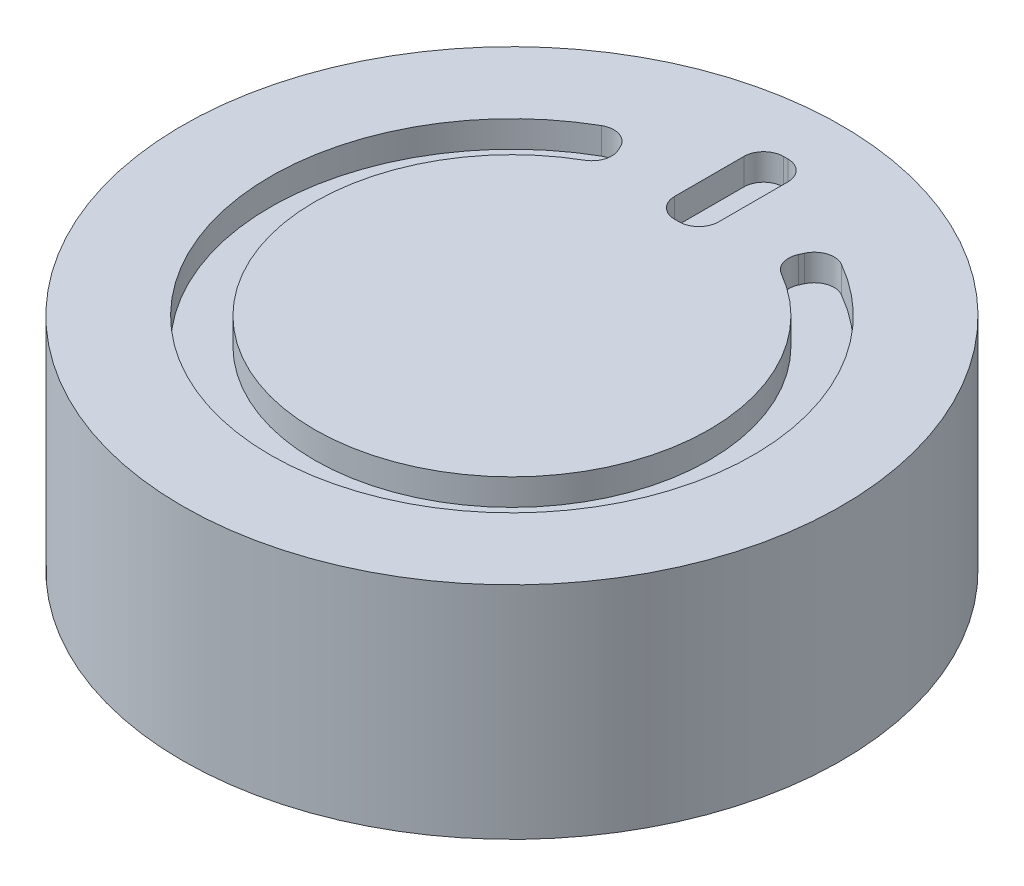
from build123d import *

# Parameters (mm, degrees)
SKETCH1_R           = 14.95
BOSS_EXTRUDE1_DEPTH = 10
CUT_EXTRUDE1_DEPTH  = 1.2


with BuildPart() as part:
    # Sketch1 → Boss-Extrude1 (new body)
    with BuildSketch(Plane(origin=(0, 0, 0), x_dir=(1, 0, 0), z_dir=(0, 1, 0))):
        with Locations(Location((0, 0, 0), (0, 0, 270))):  # turned: the seam where the file's is
            Circle(SKETCH1_R)
    extrude(amount=BOSS_EXTRUDE1_DEPTH)

    # Sketch2 → Cut-Extrude1 (cut)
    with BuildSketch(Plane(origin=(0, 10, 0), x_dir=(1, 0, 0), z_dir=(0, 1, 0))):
        with BuildLine():
            ThreePointArc((1, 8.893958624), (0, 8.95), (-1, 8.893958624))
            Line((-1, 8.893958624), (-1, 8.379586094))
            ThreePointArc((-1, 8.379586094), (-0.736396103, 7.743189991), (-0.1, 7.479586094))
            Line((-0.1, 7.479586094), (0.1, 7.479586094))
            ThreePointArc((0.1, 7.479586094), (0.736396103, 7.743189991), (1, 8.379586094))
            Line((1, 8.379586094), (1, 8.893958624))
        make_face()
        with BuildLine():
            ThreePointArc((1, 10.904242294), (0, 10.95), (-1, 10.904242294))
            Line((-1, 10.904242294), (-1, 8.893958624))
            ThreePointArc((-1, 8.893958624), (0, 8.95), (1, 8.893958624))
            Line((1, 8.893958624), (1, 10.904242294))
        make_face()
        with BuildLine():
            Line((0.1, 12.420413906), (-0.1, 12.420413906))
            ThreePointArc((-0.1, 12.420413906), (-0.736396103, 12.156810009), (-1, 11.520413906))
            Line((-1, 11.520413906), (-1, 10.904242294))
            ThreePointArc((-1, 10.904242294), (0, 10.95), (1, 10.904242294))
            Line((1, 10.904242294), (1, 11.520413906))
            ThreePointArc((1, 11.520413906), (0.736396103, 12.156810009), (0.1, 12.420413906))
        make_face()
        with BuildLine():
            ThreePointArc((-4.464100977, 7.757209709), (0, -8.95), (4.464100977, 7.757209709))
            ThreePointArc((4.464100977, 7.757209709), (4.055618077, 8.263608167), (4.095196767, 8.913016517))
            Line((4.095196767, 8.913016517), (4.179040986, 9.09549979))
            ThreePointArc((4.179040986, 9.09549979), (4.722410459, 9.57688432), (5.444328238, 9.500620508))
            ThreePointArc((5.444328238, 9.500620508), (0, -10.95), (-5.444328238, 9.500620508))
            ThreePointArc((-5.444328238, 9.500620508), (-4.722410459, 9.57688432), (-4.179040986, 9.09549979))
            Line((-4.179040986, 9.09549979), (-4.095196767, 8.913016517))
            ThreePointArc((-4.095196767, 8.913016517), (-4.055618077, 8.263608167), (-4.464100977, 7.757209709))
        make_face()
    extrude(amount=-CUT_EXTRUDE1_DEPTH, mode=Mode.SUBTRACT)


solid = part.part
